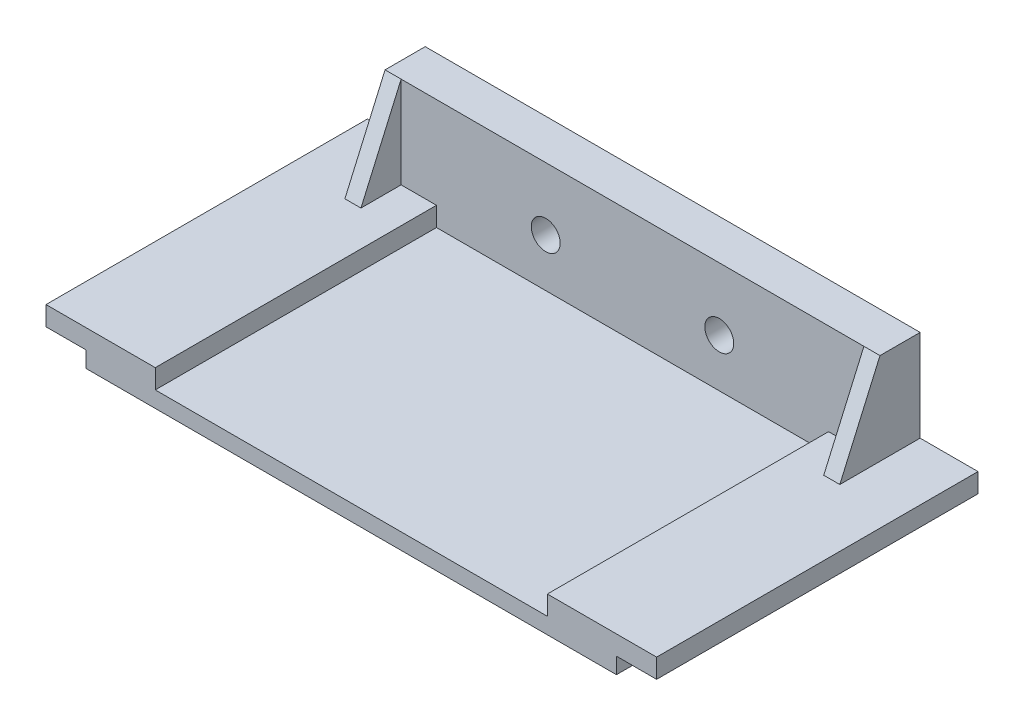
from build123d import *

# Parameters (mm, degrees)
SKETCH1_W           = 96.52
SKETCH1_H           = 50.8
BOSS_EXTRUDE1_DEPTH = 5.588
SKETCH2_W           = 61.976
SKETCH2_H           = 50.8
CUT_EXTRUDE2_DEPTH  = 3.048
SKETCH3_W           = 6.35
SKETCH3_H           = 50.8
CUT_EXTRUDE3_DEPTH  = 2.54
SKETCH4_W           = 78.232
SKETCH4_H           = 6.35
BOSS_EXTRUDE2_DEPTH = 17.526
SKETCH5_R           = 2.286
CUT_EXTRUDE4_DEPTH  = 51.8
BOSS_EXTRUDE3_DEPTH = 2.54
BOSS_EXTRUDE4_DEPTH = 2.54
SKETCH8_W           = 6.35
SKETCH8_H           = 8.89
CUT_EXTRUDE5_DEPTH  = 6.588
SKETCH9_W           = 6.35
SKETCH9_H           = 3.048
BOSS_EXTRUDE5_DEPTH = 8.89


with BuildPart() as part:
    # Sketch1 → Boss-Extrude1 (new body)
    with BuildSketch(Plane(origin=(0, 0, 0), x_dir=(1, 0, 0), z_dir=(0, 1, 0))):
        Rectangle(SKETCH1_W, SKETCH1_H)
    extrude(amount=BOSS_EXTRUDE1_DEPTH)

    # Sketch2 → Cut-Extrude2 (cut)
    with BuildSketch(Plane(origin=(0, 5.588, 0), x_dir=(1, 0, 0), z_dir=(0, 1, 0))):
        Rectangle(SKETCH2_W, SKETCH2_H)
    extrude(amount=-CUT_EXTRUDE2_DEPTH, mode=Mode.SUBTRACT)

    # Sketch3 → Cut-Extrude3 (cut)
    with BuildSketch(Plane(origin=(0, 0, 0), x_dir=(-1, 0, 0), z_dir=(0, -1, 0))):
        with Locations((-45.085, 0)):
            Rectangle(SKETCH3_W, SKETCH3_H)
        with Locations((45.085, 0)):
            Rectangle(SKETCH3_W, SKETCH3_H)
    extrude(amount=-CUT_EXTRUDE3_DEPTH, mode=Mode.SUBTRACT)

    # Sketch4 → Boss-Extrude2 (add)
    with BuildSketch(Plane(origin=(0, 2.54, 0), x_dir=(1, 0, 0), z_dir=(0, 1, 0))):
        with Locations((0, 22.225)):
            Rectangle(SKETCH4_W, SKETCH4_H)
    extrude(amount=BOSS_EXTRUDE2_DEPTH)

    # Sketch5 → Cut-Extrude4 (cut, through all)
    with BuildSketch(Plane(origin=(0, 0, -25.4), x_dir=(-1, 0, 0), z_dir=(0, 0, -1))):
        with Locations((13.716, 10.16)):
            Circle(SKETCH5_R)
        with Locations((-13.716, 10.16)):
            Circle(SKETCH5_R)
    extrude(amount=-CUT_EXTRUDE4_DEPTH, mode=Mode.SUBTRACT)

    # Sketch6 → Boss-Extrude3 (add)
    with BuildSketch(Plane.ZY.offset(39.116)):
        Polygon((-19.05, 5.588), (-12.7, 5.588), (-19.05, 20.066), align=None)
    extrude(amount=-BOSS_EXTRUDE3_DEPTH)

    # Sketch7 → Boss-Extrude4 (add)
    with BuildSketch(Plane(origin=(39.116, 0, 0), x_dir=(0, 0, -1), z_dir=(1, 0, 0))):
        Polygon((19.05, 5.588), (19.05, 20.066), (12.7, 5.588), align=None)
    extrude(amount=-BOSS_EXTRUDE4_DEPTH)

    # Sketch8 → Cut-Extrude5 (cut, through all)
    with BuildSketch(Plane(origin=(0, 5.588, 0), x_dir=(1, 0, 0), z_dir=(0, 1, 0))):
        with Locations((45.085, 20.955)):
            Rectangle(SKETCH8_W, SKETCH8_H)
        with Locations((-45.085, 20.955)):
            Rectangle(SKETCH8_W, SKETCH8_H)
    extrude(amount=-CUT_EXTRUDE5_DEPTH, mode=Mode.SUBTRACT)

    # Sketch9 → Boss-Extrude5 (add)
    with BuildSketch(Plane(origin=(0, 0, -16.51), x_dir=(-1, 0, 0), z_dir=(0, 0, -1))):
        with Locations((-45.085, 4.064)):
            Rectangle(SKETCH9_W, SKETCH9_H)
        with Locations((45.085, 4.064)):
            Rectangle(SKETCH9_W, SKETCH9_H)
    extrude(amount=BOSS_EXTRUDE5_DEPTH)


solid = part.part
